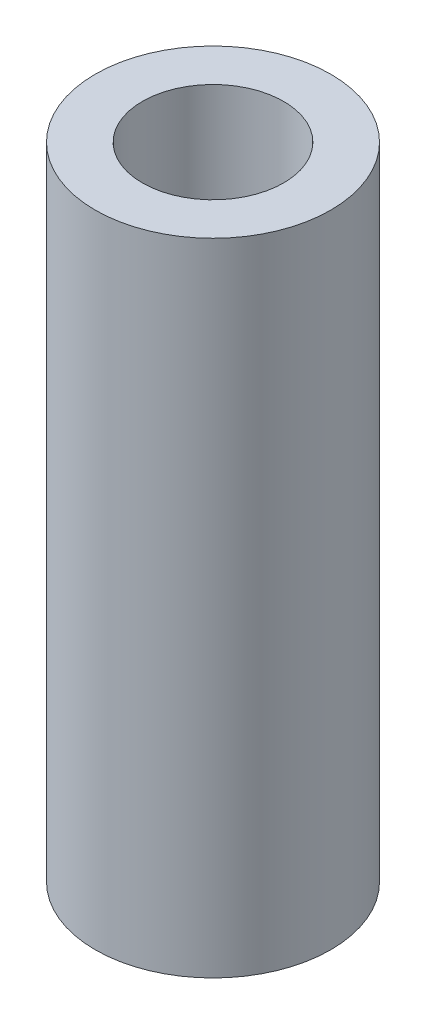
from build123d import *

# Parameters (mm, degrees)
SKETCH1_R           = 6.35
SKETCH1_R_2         = 3.81
BOSS_EXTRUDE1_DEPTH = 34.544


with BuildPart() as part:
    # Sketch1 → Boss-Extrude1 (new body)
    with BuildSketch(Plane(origin=(0, 0, 0), x_dir=(1, 0, 0), z_dir=(0, 1, 0))):
        Circle(SKETCH1_R)
        Circle(SKETCH1_R_2, mode=Mode.SUBTRACT)
    extrude(amount=BOSS_EXTRUDE1_DEPTH)


solid = part.part
